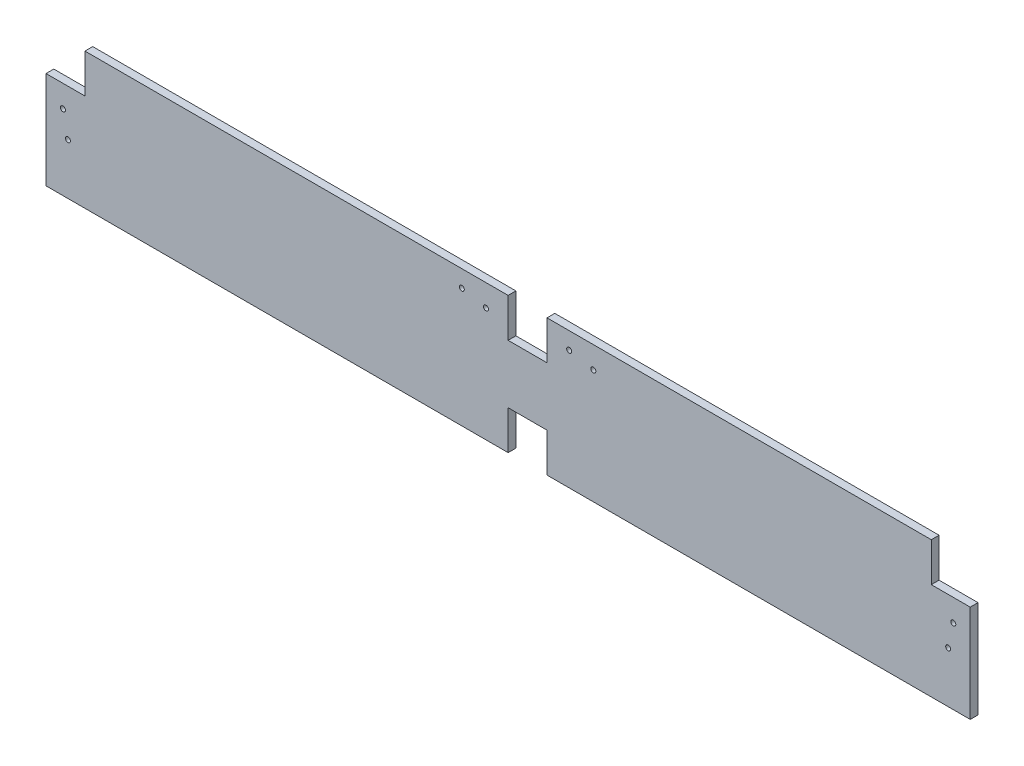
from build123d import *

# Parameters (mm, degrees)
SKETCH1_W           = 603.25
SKETCH1_H           = 88.9
BOSS_EXTRUDE1_DEPTH = 2.54
SKETCH2_W           = 25.4
SKETCH2_H           = 25.4
CUT_EXTRUDE1_DEPTH  = 5.08
SKETCH3_R           = 1.63195
CUT_EXTRUDE2_DEPTH  = 5.08
SKETCH4_R           = 1.63195
CUT_EXTRUDE3_DEPTH  = 5.08
LPATTERN1_COUNT     = 2
LPATTERN1_PITCH     = 70.104


with BuildPart() as part:
    # Sketch1 → Boss-Extrude1 (new body, symmetric)
    with BuildSketch(Plane.XY):
        Rectangle(SKETCH1_W, SKETCH1_H)
    extrude(amount=BOSS_EXTRUDE1_DEPTH, both=True)

    # Sketch2 → Cut-Extrude1 (cut)
    with BuildSketch(Plane.XY.offset(2.54)):
        with Locations((-288.925, 31.75)):
            Rectangle(SKETCH2_W, SKETCH2_H)
        with Locations((288.925, 31.75)):
            Rectangle(SKETCH2_W, SKETCH2_H)
        with Locations((12.7, 31.75)):
            Rectangle(SKETCH2_W, SKETCH2_H)
        with Locations((12.7, -31.75)):
            Rectangle(SKETCH2_W, SKETCH2_H)
    extrude(amount=-CUT_EXTRUDE1_DEPTH, mode=Mode.SUBTRACT)

    # Sketch3 → Cut-Extrude2 (cut)
    with BuildSketch(Plane.XY.offset(2.54)):
        with Locations((-14.478, 30.099)):
            Circle(SKETCH3_R)
        with Locations((-30.226, 33.401)):
            Circle(SKETCH3_R)
    cut_extrude2 = extrude(amount=-CUT_EXTRUDE2_DEPTH, mode=Mode.SUBTRACT)

    # Sketch4 → Cut-Extrude3 (cut)
    with BuildSketch(Plane.XY.offset(2.54)):
        with Locations((-290.576, 4.572)):
            Circle(SKETCH4_R)
        with Locations((-287.274, -11.176)):
            Circle(SKETCH4_R)
    cut_extrude3 = extrude(amount=-CUT_EXTRUDE3_DEPTH, mode=Mode.SUBTRACT)

    # Mirror2: Cut-Extrude3 across plane
    add(cut_extrude3.mirror(Plane(origin=(0, 0, 0), x_dir=(0, 0, 1), z_dir=(1, 0, 0))), mode=Mode.SUBTRACT)

    # LPattern1: Cut-Extrude2 ×2
    with Locations(*[(i * LPATTERN1_PITCH, 0, 0) for i in range(1, LPATTERN1_COUNT)]):
        add(cut_extrude2, mode=Mode.SUBTRACT)


solid = part.part
